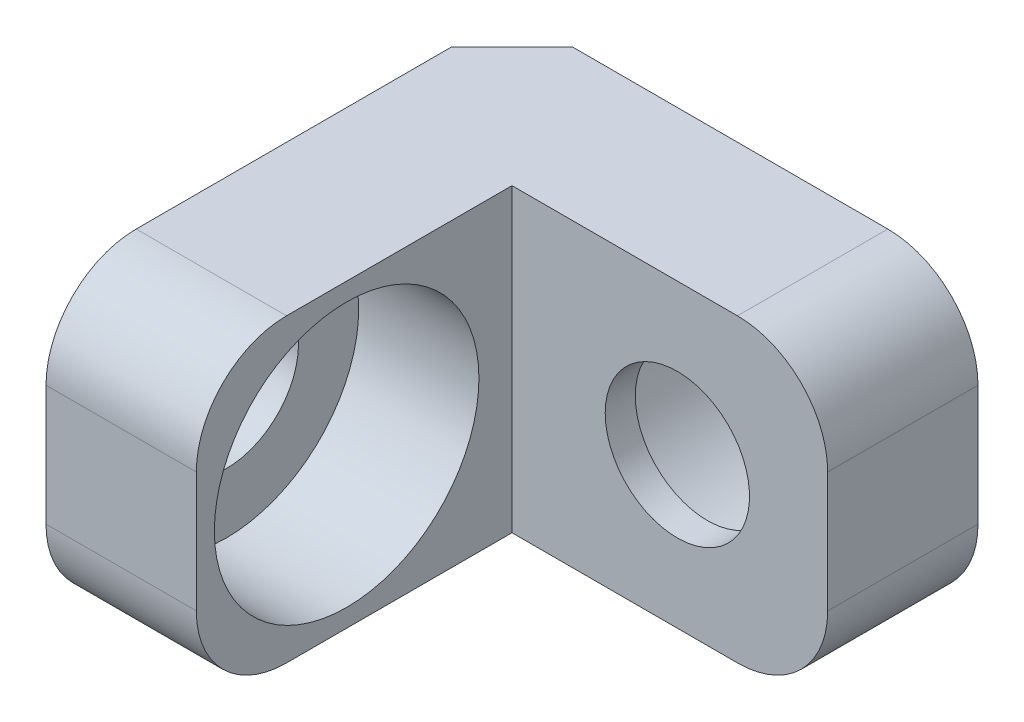
from build123d import *

# Parameters (mm, degrees)
BOSS_EXTRUDE2_DEPTH            = 5
CHAMFER1_SIZE                  = 1
CBORE_FOR_M2_SHCS1_D           = 2.4
CBORE_FOR_M2_SHCS1_CBORE_D     = 4.4
CBORE_FOR_M2_SHCS1_CBORE_DEPTH = 2
FILLET2_R                      = 1.5
CBORE_FOR_M2_SHCS3_D           = 2.4
CBORE_FOR_M2_SHCS3_CBORE_D     = 4.4
CBORE_FOR_M2_SHCS3_CBORE_DEPTH = 2


with BuildPart() as part:
    # Sketch1 → Boss-Extrude2 (new body)
    with BuildSketch(Plane(origin=(0, 0, 0), x_dir=(1, 0, 0), z_dir=(0, 1, 0))):
        Polygon((0, 0), (0, 7.75), (7.75, 7.75), (7.75, 5.25), (2.5, 5.25), (2.5, 0), align=None)
    extrude(amount=BOSS_EXTRUDE2_DEPTH)

    # Chamfer1
    chamfer1_edges = [part.edges().sort_by_distance(p)[0] for p in [
        (0, 2.5, -7.75),
    ]]
    chamfer(chamfer1_edges, length=CHAMFER1_SIZE)

    # CBORE for M2 SHCS1 (through all)
    with Locations(Plane(origin=(0, 0, -7.75), x_dir=(-1, 0, 0), z_dir=(0, 0, -1))):
        with Locations((-5.25, 2.5)):
            CounterBoreHole(CBORE_FOR_M2_SHCS1_D / 2, CBORE_FOR_M2_SHCS1_CBORE_D / 2, CBORE_FOR_M2_SHCS1_CBORE_DEPTH)

    # Fillet2
    fillet2_edges = [part.edges().sort_by_distance(p)[0] for p in [
        (7.75, 5, -6.5),
        (1.25, 5, 0),
        (7.75, 0, -6.5),
        (1.25, 0, 0),
    ]]
    fillet(fillet2_edges, radius=FILLET2_R)

    # CBORE for M2 SHCS3 (through all)
    with Locations(Plane(origin=(2.5, 0, 0), x_dir=(0, 0, -1), z_dir=(1, 0, 0))):
        with Locations((2.5, 2.5)):
            CounterBoreHole(CBORE_FOR_M2_SHCS3_D / 2, CBORE_FOR_M2_SHCS3_CBORE_D / 2, CBORE_FOR_M2_SHCS3_CBORE_DEPTH)


solid = part.part
